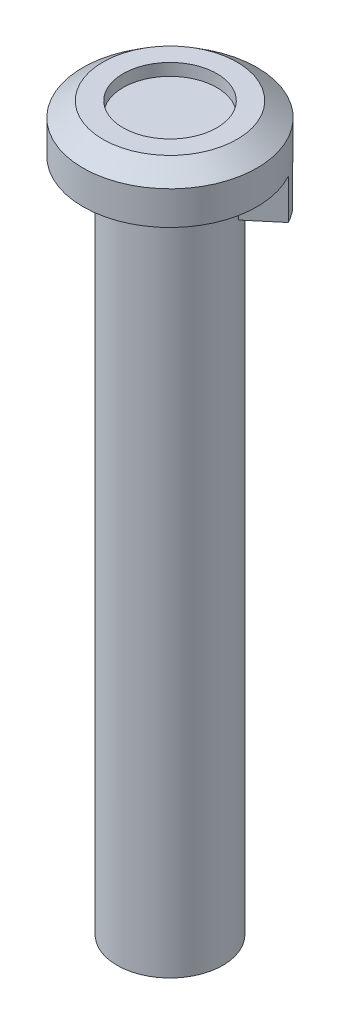
from build123d import *

# Parameters (mm, degrees)
SKETCH1_W           = 3.95
SKETCH1_H           = 50.3
BOSS_EXTRUDE1_DEPTH = 1.25
SKETCH4_W           = 6.5
SKETCH4_H           = 3
BOSS_EXTRUDE2_DEPTH = 1.25
SKETCH5_OUTSIDE_W   = 26.39
SKETCH5_OUTSIDE_H   = 26.39
SKETCH5_OUTSIDE_R   = 6.5
CUT_EXTRUDE1_DEPTH  = 55.678240645


with BuildPart() as part:
    # Sketch1 → Revolve1 (revolve)
    with BuildSketch(Plane.XY):
        with Locations((1.975, -25.15)):
            Rectangle(SKETCH1_W, SKETCH1_H)
    revolve(axis=Axis((0, 6.295, 0), (0, -1, 0)))

    # Sketch2 → Revolve2 (revolve)
    with BuildSketch(Plane.XY):
        Polygon((0, 0), (6.5, 0), (6.5, 2.5), (5, 3.6), (3.5, 3.6), (3.5, 2.7), (0, 2.7), align=None)
    revolve(axis=Axis((0, 6.295, 0), (0, -1, 0)))

    # Sketch3 → Boss-Extrude1 (add)
    with BuildSketch(Plane(origin=(0, 0, 0), x_dir=(0.7660444431189771, 0, -0.6427876096865406), z_dir=(0.6427876096865406, 0, 0.7660444431189771))):
        Polygon((0, 0), (6.5, 0), (0, -6.5), align=None)
    extrude(amount=-BOSS_EXTRUDE1_DEPTH)

    # Sketch4 → Boss-Extrude2 (add)
    with BuildSketch(Plane(origin=(0, 0, 0), x_dir=(0.7660444431189771, 0, -0.6427876096865406), z_dir=(0.6427876096865406, 0, 0.7660444431189771))):
        with Locations((3.25, -1.5)):
            Rectangle(SKETCH4_W, SKETCH4_H)
    extrude(amount=BOSS_EXTRUDE2_DEPTH)

    # Sketch5 outside → Cut-Extrude1 (cut, through all)
    with BuildSketch(Plane(origin=(0, 3.6, 0), x_dir=(1, 0, 0), z_dir=(0, 1, 0))):
        Rectangle(SKETCH5_OUTSIDE_W, SKETCH5_OUTSIDE_H)
        Circle(SKETCH5_OUTSIDE_R, mode=Mode.SUBTRACT)
    extrude(amount=-CUT_EXTRUDE1_DEPTH, mode=Mode.SUBTRACT)


solid = part.part
